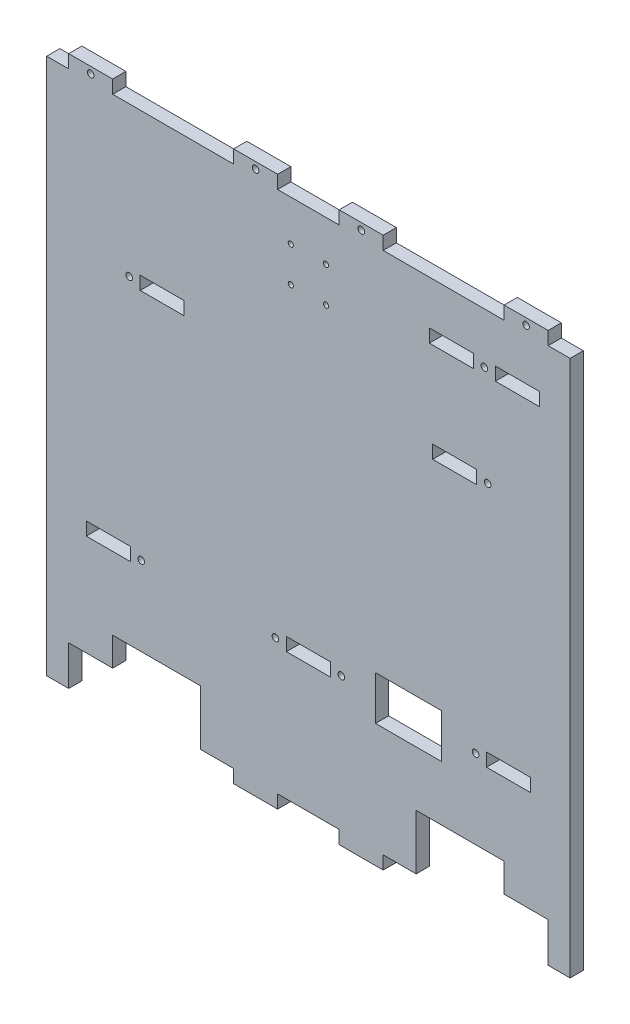
from build123d import *

# Parameters (mm, degrees)
ESQUISSE1_W             = 218
ESQUISSE1_H             = 238
ESQUISSE1_W_2           = 20
ESQUISSE1_H_2           = 6
ESQUISSE1_W_3           = 30
ESQUISSE1_H_3           = 20
BOSS_EXTRU_1_DEPTH      = 6
ESQUISSE2_W             = 40
ESQUISSE2_H             = 25
ENL_V_MAT_EXTRU_1_DEPTH = 6
ESQUISSE3_W             = 20
ESQUISSE3_H             = 6
BOSS_EXTRU_3_DEPTH      = 6
ESQUISSE4_R             = 1.5
ENL_V_MAT_EXTRU_2_DEPTH = 6
ESQUISSE5_W             = 10
ESQUISSE5_H             = 244
BOSS_EXTRU_4_DEPTH      = 6
ESQUISSE6_W             = 20
ESQUISSE6_H             = 12
ENL_V_MAT_EXTRU_3_DEPTH = 6
ESQUISSE7_R             = 1.175
ENL_V_MAT_EXTRU_4_DEPTH = 7


with BuildPart() as part:
    # Esquisse1 → Boss.-Extru.1 (new body)
    with BuildSketch(Plane.XY):
        Rectangle(ESQUISSE1_W, ESQUISSE1_H)
        with Locations((-91, -58)):
            Rectangle(ESQUISSE1_W_2, ESQUISSE1_H_2, mode=Mode.SUBTRACT)
        with Locations((0, -58)):
            Rectangle(ESQUISSE1_W_2, ESQUISSE1_H_2, mode=Mode.SUBTRACT)
        with Locations((91, -58)):
            Rectangle(ESQUISSE1_W_2, ESQUISSE1_H_2, mode=Mode.SUBTRACT)
        with Locations((-66.5, 51)):
            Rectangle(ESQUISSE1_W_2, ESQUISSE1_H_2, mode=Mode.SUBTRACT)
        with Locations((66.5, 51)):
            Rectangle(ESQUISSE1_W_2, ESQUISSE1_H_2, mode=Mode.SUBTRACT)
        with Locations((45.5, -59)):
            Rectangle(ESQUISSE1_W_3, ESQUISSE1_H_3, mode=Mode.SUBTRACT)
        with Locations((65, 96)):
            Rectangle(ESQUISSE1_W_2, ESQUISSE1_H_2, mode=Mode.SUBTRACT)
        with Locations((95, 96)):
            Rectangle(ESQUISSE1_W_2, ESQUISSE1_H_2, mode=Mode.SUBTRACT)
    extrude(amount=BOSS_EXTRU_1_DEPTH)

    # Esquisse2 → Enlèv. mat.-Extru.1 (cut)
    with BuildSketch(Plane.XY.offset(6)):
        with Locations((-69, -106.5)):
            Rectangle(ESQUISSE2_W, ESQUISSE2_H)
        with Locations((69, -106.5)):
            Rectangle(ESQUISSE2_W, ESQUISSE2_H)
    extrude(amount=-ENL_V_MAT_EXTRU_1_DEPTH, mode=Mode.SUBTRACT)

    # Esquisse3 → Boss.-Extru.3 (add)
    with BuildSketch(Plane.XY.offset(6)):
        with Locations((-24, -122)):
            Rectangle(ESQUISSE3_W, ESQUISSE3_H)
        with Locations((24, -122)):
            Rectangle(ESQUISSE3_W, ESQUISSE3_H)
        with Locations((24, 122)):
            Rectangle(ESQUISSE3_W, ESQUISSE3_H)
        with Locations((99, 122)):
            Rectangle(ESQUISSE3_W, ESQUISSE3_H)
        with Locations((-24, 122)):
            Rectangle(ESQUISSE3_W, ESQUISSE3_H)
        with Locations((-99, 122)):
            Rectangle(ESQUISSE3_W, ESQUISSE3_H)
    extrude(amount=-BOSS_EXTRU_3_DEPTH)

    # Esquisse4 → Enlèv. mat.-Extru.2 (cut)
    with BuildSketch(Plane.XY.offset(6)):
        with Locations((-15, -58)):
            Circle(ESQUISSE4_R)
        with Locations((-76, -58)):
            Circle(ESQUISSE4_R)
        with Locations((80, 96)):
            Circle(ESQUISSE4_R)
        with Locations((81.5, 51)):
            Circle(ESQUISSE4_R)
        with Locations((76, -58)):
            Circle(ESQUISSE4_R)
        with Locations((15, -58)):
            Circle(ESQUISSE4_R)
        with Locations((-81.5, 51)):
            Circle(ESQUISSE4_R)
        with Locations((-99, 122)):
            Circle(ESQUISSE4_R)
        with Locations((-24, 122)):
            Circle(ESQUISSE4_R)
        with Locations((24, 122)):
            Circle(ESQUISSE4_R)
        with Locations((99, 122)):
            Circle(ESQUISSE4_R)
    extrude(amount=-ENL_V_MAT_EXTRU_2_DEPTH, mode=Mode.SUBTRACT)

    # Esquisse5 → Boss.-Extru.4 (add)
    with BuildSketch(Plane.XY.offset(6)):
        with Locations((-114, -3)):
            Rectangle(ESQUISSE5_W, ESQUISSE5_H)
        with Locations((114, -3)):
            Rectangle(ESQUISSE5_W, ESQUISSE5_H)
    extrude(amount=-BOSS_EXTRU_4_DEPTH)

    # Esquisse6 → Enlèv. mat.-Extru.3 (cut)
    with BuildSketch(Plane.XY.offset(6)):
        with Locations((99, -113)):
            Rectangle(ESQUISSE6_W, ESQUISSE6_H)
        with Locations((-99, -113)):
            Rectangle(ESQUISSE6_W, ESQUISSE6_H)
    extrude(amount=-ENL_V_MAT_EXTRU_3_DEPTH, mode=Mode.SUBTRACT)

    # Esquisse7 → Enlèv. mat.-Extru.4 (cut, through all)
    with BuildSketch(Plane.XY.offset(6)):
        with Locations((-8, 100.5)):
            Circle(ESQUISSE7_R)
        with Locations((8, 100.5)):
            Circle(ESQUISSE7_R)
        with Locations((-8, 84.5)):
            Circle(ESQUISSE7_R)
        with Locations((8, 84.5)):
            Circle(ESQUISSE7_R)
    extrude(amount=-ENL_V_MAT_EXTRU_4_DEPTH, mode=Mode.SUBTRACT)


solid = part.part
